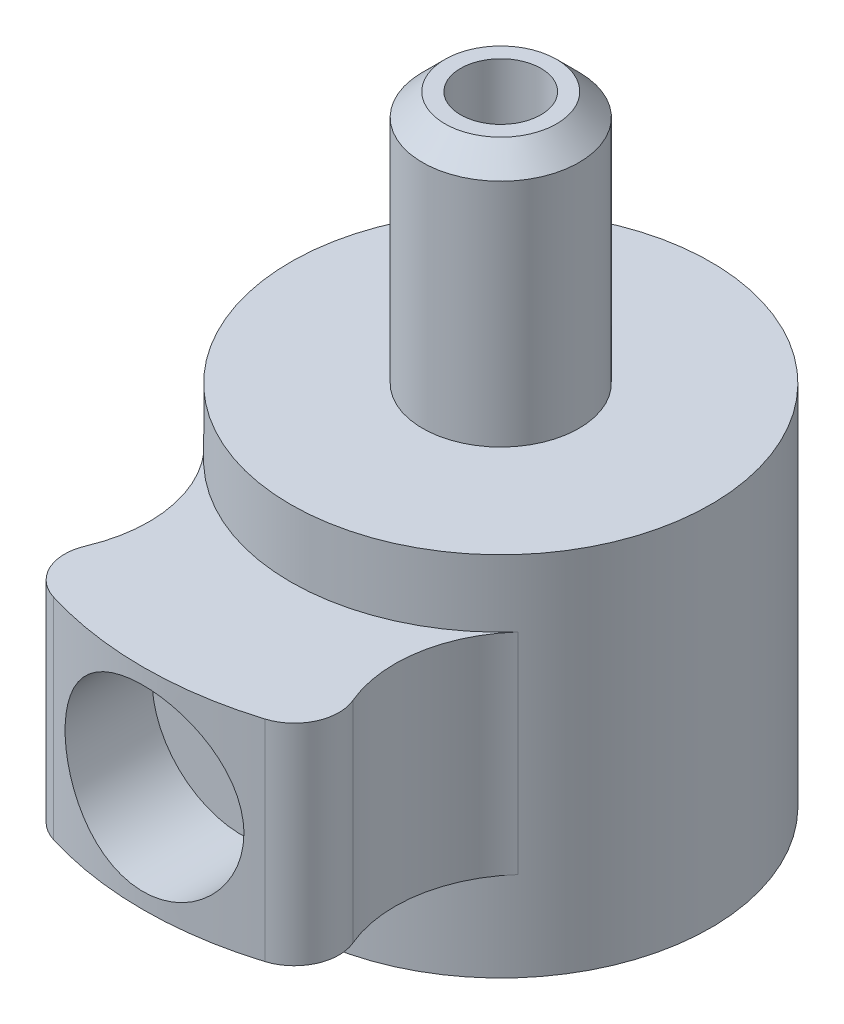
from build123d import *

# Parameters (mm, degrees)
CUT_EXTRUDE_1_DEPTH   = 9.2
FILLET_1_R            = 1
SKETCH_5_OUTSIDE_W    = 15.602
SKETCH_5_OUTSIDE_H    = 18.902
SKETCH_5_OUTSIDE_R    = 4.7
CUT_EXTRUDE_4_DEPTH   = 1.5
CUT_EXTRUDE_START     = -8.2
SKETCH_5_2_OUTSIDE_W  = 15.602
SKETCH_5_2_OUTSIDE_H  = 18.902
SKETCH_5_2_OUTSIDE_R  = 4.7
CUT_EXTRUDE_5_DEPTH   = 2
CHAMFER_1_SIZE        = 0.5
M2_TAPPED_HOLE1_D     = 1.6
M2_TAPPED_HOLE1_DEPTH = 5.2
M2_TAPPED_HOLE1_TIP   = 0.480688495
SKETCH4_R             = 2
CUT_EXTRUDE1_DEPTH    = 2.2


with BuildPart() as part:
    # Эскиз1 → Повернуть1 (revolve)
    with BuildSketch(Plane(origin=(0, 0, 0), x_dir=(0, 0, -1), z_dir=(1, 0, 0))):
        Polygon((-3.4, 0), (-3.4, 6.5), (-0.9, 6.5), (-0.9, 13.85), (-1.75, 13.85), (-1.75, 8.2), (-8, 8.2), (-8, 0), align=None)
    revolve(axis=Axis((0, 0, 0), (0, 1, 0)))

    # Эскиз2 → Вырез-Вытянуть1 (cut, through all)
    with BuildSketch(Plane(origin=(0, 8.2, 0), x_dir=(1, 0, 0), z_dir=(0, 1, 0))):
        with BuildLine():
            ThreePointArc((7.99025974, -7.116582697), (0, 10.7), (-7.99025974, -7.116582697))
            ThreePointArc((-7.99025974, -7.116582697), (-3.75469644, -7.361538877), (-3.50974026, -3.125975577))
            ThreePointArc((-3.50974026, -3.125975577), (0, 4.7), (3.50974026, -3.125975577))
            ThreePointArc((3.50974026, -3.125975577), (3.75469644, -7.361538877), (7.99025974, -7.116582697))
        make_face()
    extrude(amount=-CUT_EXTRUDE_1_DEPTH, mode=Mode.SUBTRACT)

    # Скругление1
    fillet_1_edges = [part.edges().sort_by_distance(p)[0] for p in [
        (-3.555293146, 4.1, 7.166581517),
        (3.555293146, 4.1, 7.166581517),
    ]]
    fillet(fillet_1_edges, radius=FILLET_1_R)

    # Эскиз5 outside → Вырез-Вытянуть4 (cut)
    with BuildSketch(Plane(origin=(0, 8.2, 0), x_dir=(1, 0, 0), z_dir=(0, 1, 0))):
        with Locations((0, -1.65)):
            Rectangle(SKETCH_5_OUTSIDE_W, SKETCH_5_OUTSIDE_H)
        Circle(SKETCH_5_OUTSIDE_R, mode=Mode.SUBTRACT)
    extrude(amount=-CUT_EXTRUDE_4_DEPTH, mode=Mode.SUBTRACT)

    # Эскиз5<2> outside → Вырез-Вытянуть5 (cut)
    with BuildSketch(Plane(origin=(0, 8.2, 0), x_dir=(1, 0, 0), z_dir=(0, 1, 0)).offset(CUT_EXTRUDE_START)):
        with Locations((0, -1.65)):
            Rectangle(SKETCH_5_2_OUTSIDE_W, SKETCH_5_2_OUTSIDE_H)
        Circle(SKETCH_5_2_OUTSIDE_R, mode=Mode.SUBTRACT)
    extrude(amount=CUT_EXTRUDE_5_DEPTH, mode=Mode.SUBTRACT)

    # Фаска1
    chamfer_1_edges = [part.edges().sort_by_distance(p)[0] for p in [
        (0, 13.85, -1.75),
    ]]
    chamfer(chamfer_1_edges, length=CHAMFER_1_SIZE)

    # M2 Tapped Hole1
    with Locations(Plane(origin=(0, 8.2, 8), x_dir=(1, 0, 0), z_dir=(0, 0, 1))):
        with Locations((0, -3.85)):
            Hole(M2_TAPPED_HOLE1_D / 2, depth=M2_TAPPED_HOLE1_DEPTH)
            with Locations((0, 0, -(M2_TAPPED_HOLE1_DEPTH + M2_TAPPED_HOLE1_TIP / 2))):  # 118° drill point
                Cone(0, M2_TAPPED_HOLE1_D / 2, M2_TAPPED_HOLE1_TIP, mode=Mode.SUBTRACT)

    # Sketch4 → Cut-Extrude1 (cut)
    with BuildSketch(Plane(origin=(0, 8.2, 8), x_dir=(1, 0, 0), z_dir=(0, 0, 1))):
        with Locations((0, -3.85)):
            Circle(SKETCH4_R)
    extrude(amount=-CUT_EXTRUDE1_DEPTH, mode=Mode.SUBTRACT)


solid = part.part
